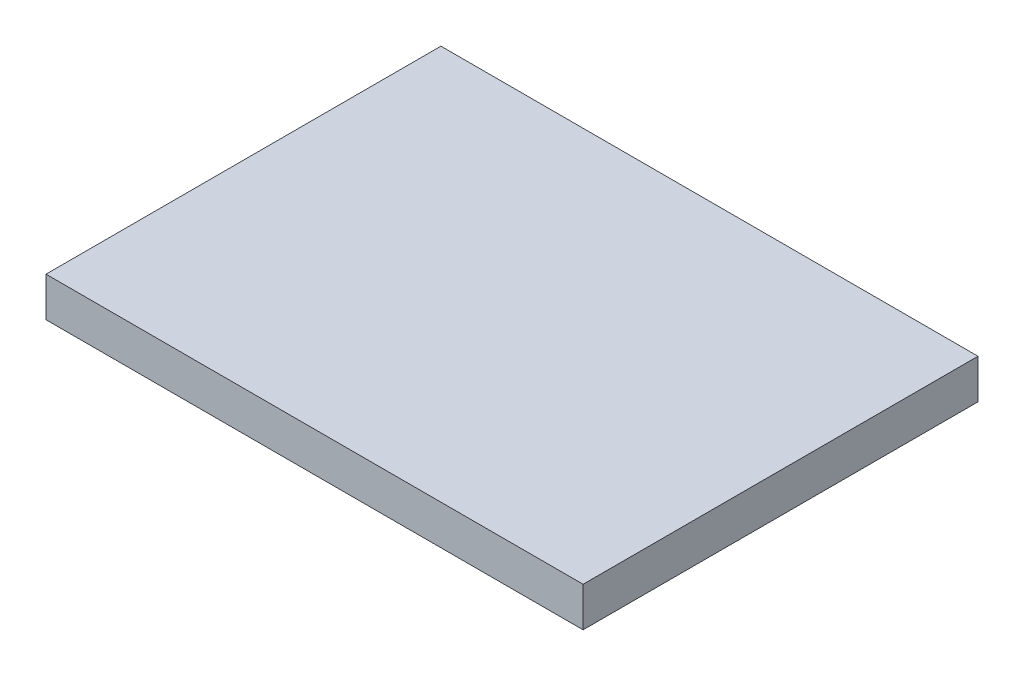
from build123d import *

# Parameters (mm, degrees)
SKETCH1_W           = 340
SKETCH1_H           = 250
BOSS_EXTRUDE1_DEPTH = 25


with BuildPart() as part:
    # Sketch1 → Boss-Extrude1 (new body)
    with BuildSketch(Plane(origin=(0, 0, 0), x_dir=(1, 0, 0), z_dir=(0, 1, 0))):
        with Locations((170, 125)):
            Rectangle(SKETCH1_W, SKETCH1_H)
    extrude(amount=BOSS_EXTRUDE1_DEPTH)


solid = part.part
